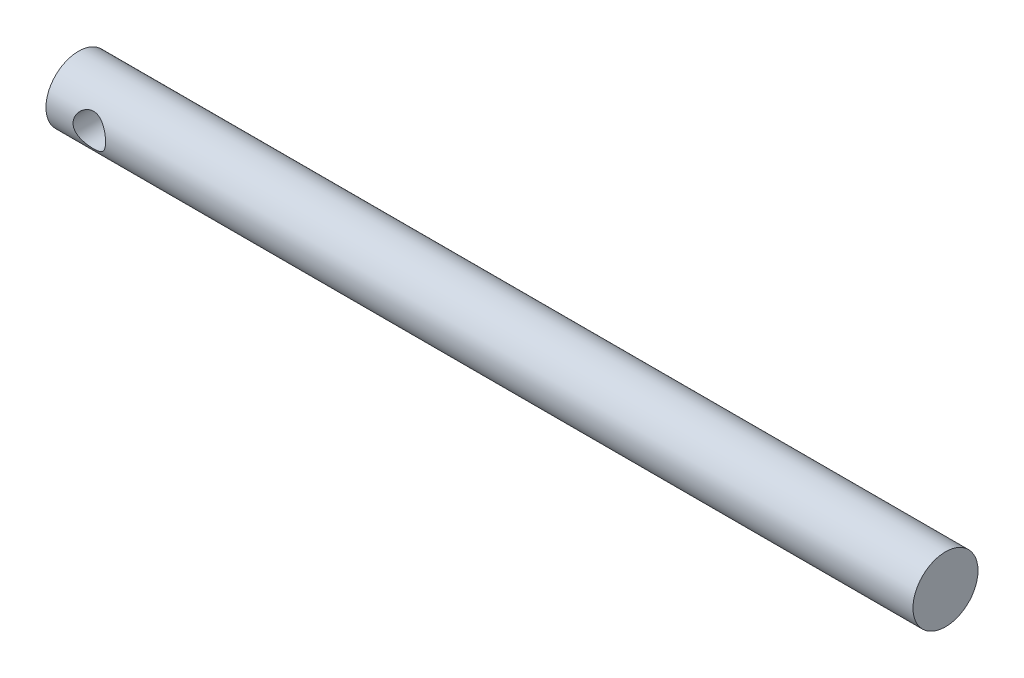
from build123d import *

# Parameters (mm, degrees)
SKETCH_1_R               = 3
EXTRUDE_1_DEPTH          = 40
SKETCH_2_R               = 1.5
CUT_EXTRUDE_1_DEPTH      = 4
CUT_EXTRUDE_1_DEPTH_BACK = 4


with BuildPart() as part:
    # 草圖1 → 填料-伸長1 (new body, symmetric)
    with BuildSketch(Plane(origin=(0, 0, 0), x_dir=(0, 0, -1), z_dir=(1, 0, 0))):
        Circle(SKETCH_1_R)
    extrude(amount=EXTRUDE_1_DEPTH, both=True)

    # 草圖2 → 除料-伸長1 (cut, two sides)
    with BuildSketch(Plane.XY) as cut_extrude_1_sk:
        with Locations((-36, 0)):
            Circle(SKETCH_2_R)
    extrude(amount=CUT_EXTRUDE_1_DEPTH, mode=Mode.SUBTRACT)
    extrude(cut_extrude_1_sk.sketch, amount=-CUT_EXTRUDE_1_DEPTH_BACK, mode=Mode.SUBTRACT)


solid = part.part
